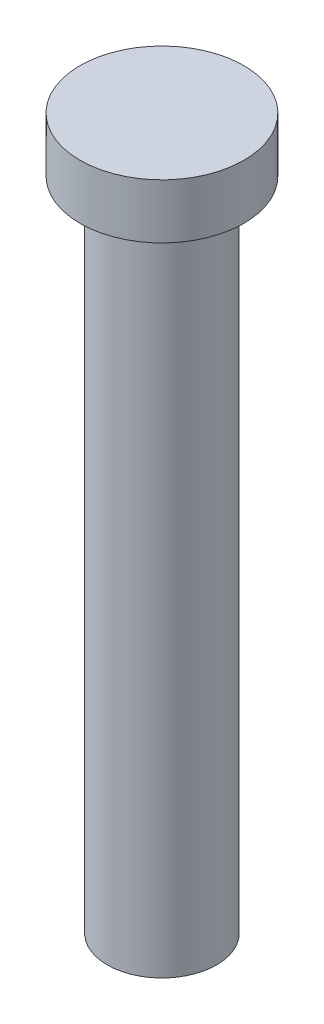
from build123d import *

# Parameters (mm, degrees)
SKETCH1_R           = 6.35
BOSS_EXTRUDE1_DEPTH = 76.2
SKETCH2_R           = 9.525
BOSS_EXTRUDE2_DEPTH = 6.35


with BuildPart() as part:
    # Sketch1 → Boss-Extrude1 (new body)
    with BuildSketch(Plane(origin=(0, 0, 0), x_dir=(1, 0, 0), z_dir=(0, 1, 0))):
        Circle(SKETCH1_R)
    extrude(amount=BOSS_EXTRUDE1_DEPTH)

    # Sketch2 → Boss-Extrude2 (add)
    with BuildSketch(Plane(origin=(0, 76.2, 0), x_dir=(1, 0, 0), z_dir=(0, 1, 0))):
        Circle(SKETCH2_R)
    extrude(amount=BOSS_EXTRUDE2_DEPTH)


solid = part.part
